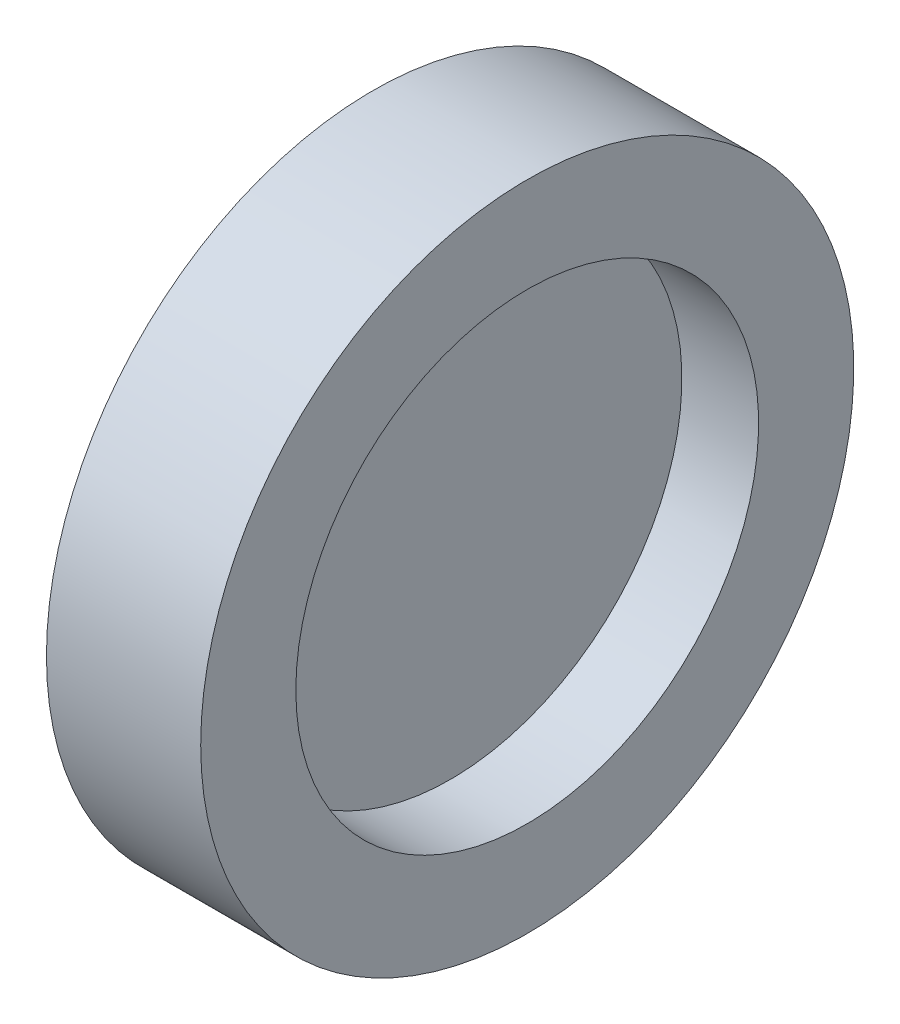
from build123d import *

# Parameters (mm, degrees)
SKETCH_1_W = 0.03
SKETCH_1_H = 9
SKETCH_4_W = 6
SKETCH_4_H = 3.7


with BuildPart() as part:
    # 草图1 → 旋转2 (revolve)
    with BuildSketch(Plane.XY, mode=Mode.PRIVATE) as revolve_2_sk:
        with Locations((0, 4.5)):
            Rectangle(SKETCH_1_W, SKETCH_1_H)
    revolve(revolve_2_sk.sketch.rotate(Axis((-0.015, 0, 0), (1, 0, 0)), 90), axis=Axis((-0.015, 0, 0), (1, 0, 0)))  # turned: the seam where the file's is

    # 草图4 → 旋转3 (revolve)
    with BuildSketch(Plane.XY, mode=Mode.PRIVATE) as revolve_3_sk:
        with Locations((0, 10.85)):
            Rectangle(SKETCH_4_W, SKETCH_4_H)
    revolve(revolve_3_sk.sketch.rotate(Axis((-1.614212419, 0, 0), (1, 0, 0)), 90), axis=Axis((-1.614212419, 0, 0), (1, 0, 0)))  # turned: the seam where the file's is


solid = part.part
